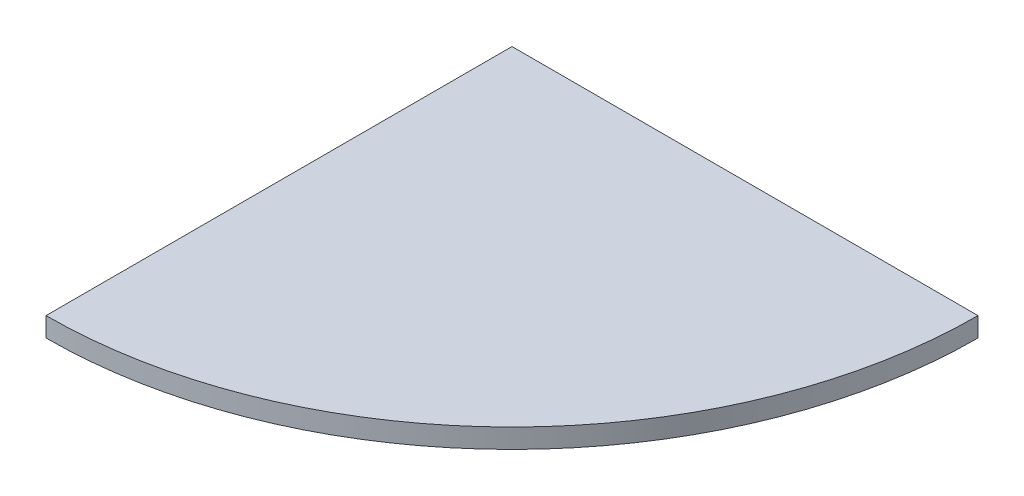
from build123d import *

# Parameters (mm, degrees)
BOSS_EXTRUDE1_DEPTH = 18


with BuildPart() as part:
    # Sketch1 → Boss-Extrude1 (new body)
    with BuildSketch(Plane(origin=(0, 0, 0), x_dir=(1, 0, 0), z_dir=(0, 1, 0))):
        with BuildLine():
            Line((0, 0), (0, -432))
            ThreePointArc((0, -432), (305.470129473, -305.470129473), (432, 0))
            Line((432, 0), (0, 0))
        make_face()
    extrude(amount=BOSS_EXTRUDE1_DEPTH)


solid = part.part
